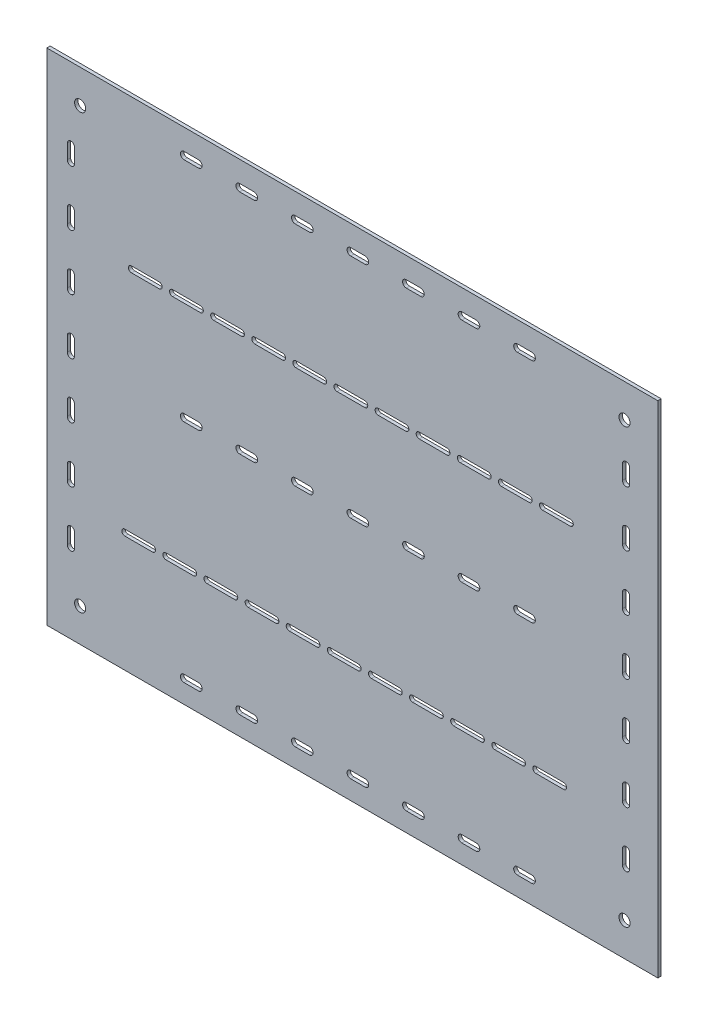
from build123d import *

# Parameters (mm, degrees)
CROQUIS1_W              = 550
CROQUIS1_H              = 450
CROQUIS1_R              = 5
SALIENTE_EXTRUIR1_DEPTH = 3


with BuildPart() as part:
    # Croquis1 → Saliente-Extruir1 (new body)
    with BuildSketch(Plane(origin=(0, 0, 0), x_dir=(-1, 0, 0), z_dir=(0, 0, -1))):
        Rectangle(CROQUIS1_W, CROQUIS1_H)
        with Locations((-245, -195)):
            Circle(CROQUIS1_R, mode=Mode.SUBTRACT)
        with Locations((245, -195)):
            Circle(CROQUIS1_R, mode=Mode.SUBTRACT)
        with Locations((-245, 195)):
            Circle(CROQUIS1_R, mode=Mode.SUBTRACT)
        with Locations((245, 195)):
            Circle(CROQUIS1_R, mode=Mode.SUBTRACT)
        with BuildLine():
            Line((250.09614838, 147), (250.09614838, 160))
            ThreePointArc((250.09614838, 160), (253.34614838, 163.25), (256.59614838, 160))
            Line((256.59614838, 160), (256.59614838, 147))
            ThreePointArc((256.59614838, 147), (253.34614838, 143.75), (250.09614838, 147))
        make_face(mode=Mode.SUBTRACT)
        with BuildLine():
            Line((19.81708851, -120.391388581), (-5.18291149, -120.391388581))
            ThreePointArc((-5.18291149, -120.391388581), (-7.88291149, -117.691388581), (-5.18291149, -114.991388581))
            Line((-5.18291149, -114.991388581), (19.81708851, -114.991388581))
            ThreePointArc((19.81708851, -114.991388581), (22.51708851, -117.691388581), (19.81708851, -120.391388581))
        make_face(mode=Mode.SUBTRACT)
        with BuildLine():
            Line((-128.18291149, -120.391388581), (-153.18291149, -120.391388581))
            ThreePointArc((-153.18291149, -120.391388581), (-155.88291149, -117.691388581), (-153.18291149, -114.991388581))
            Line((-153.18291149, -114.991388581), (-128.18291149, -114.991388581))
            ThreePointArc((-128.18291149, -114.991388581), (-125.48291149, -117.691388581), (-128.18291149, -120.391388581))
        make_face(mode=Mode.SUBTRACT)
        with BuildLine():
            Line((93.81708851, -120.391388581), (68.81708851, -120.391388581))
            ThreePointArc((68.81708851, -120.391388581), (66.11708851, -117.691388581), (68.81708851, -114.991388581))
            Line((68.81708851, -114.991388581), (93.81708851, -114.991388581))
            ThreePointArc((93.81708851, -114.991388581), (96.51708851, -117.691388581), (93.81708851, -120.391388581))
        make_face(mode=Mode.SUBTRACT)
        with BuildLine():
            Line((-17.18291149, -120.391388581), (-42.18291149, -120.391388581))
            ThreePointArc((-42.18291149, -120.391388581), (-44.88291149, -117.691388581), (-42.18291149, -114.991388581))
            Line((-42.18291149, -114.991388581), (-17.18291149, -114.991388581))
            ThreePointArc((-17.18291149, -114.991388581), (-14.48291149, -117.691388581), (-17.18291149, -120.391388581))
        make_face(mode=Mode.SUBTRACT)
        with BuildLine():
            Line((167.81708851, -120.391388581), (142.81708851, -120.391388581))
            ThreePointArc((142.81708851, -120.391388581), (140.11708851, -117.691388581), (142.81708851, -114.991388581))
            Line((142.81708851, -114.991388581), (167.81708851, -114.991388581))
            ThreePointArc((167.81708851, -114.991388581), (170.51708851, -117.691388581), (167.81708851, -120.391388581))
        make_face(mode=Mode.SUBTRACT)
        with BuildLine():
            Line((56.81708851, -120.391388581), (31.81708851, -120.391388581))
            ThreePointArc((31.81708851, -120.391388581), (29.11708851, -117.691388581), (31.81708851, -114.991388581))
            Line((31.81708851, -114.991388581), (56.81708851, -114.991388581))
            ThreePointArc((56.81708851, -114.991388581), (59.51708851, -117.691388581), (56.81708851, -120.391388581))
        make_face(mode=Mode.SUBTRACT)
        with BuildLine():
            Line((179.81708851, -114.991388581), (204.81708851, -114.991388581))
            ThreePointArc((204.81708851, -114.991388581), (207.51708851, -117.691388581), (204.81708851, -120.391388581))
            Line((204.81708851, -120.391388581), (179.81708851, -120.391388581))
            ThreePointArc((179.81708851, -120.391388581), (177.11708851, -117.691388581), (179.81708851, -114.991388581))
        make_face(mode=Mode.SUBTRACT)
        with BuildLine():
            Line((105.81708851, -114.991388581), (130.81708851, -114.991388581))
            ThreePointArc((130.81708851, -114.991388581), (133.51708851, -117.691388581), (130.81708851, -120.391388581))
            Line((130.81708851, -120.391388581), (105.81708851, -120.391388581))
            ThreePointArc((105.81708851, -120.391388581), (103.11708851, -117.691388581), (105.81708851, -114.991388581))
        make_face(mode=Mode.SUBTRACT)
        with BuildLine():
            Line((-171.181949448, 87.805486707), (-196.181949448, 87.805486707))
            ThreePointArc((-196.181949448, 87.805486707), (-198.881949448, 90.505486707), (-196.181949448, 93.205486707))
            Line((-196.181949448, 93.205486707), (-171.181949448, 93.205486707))
            ThreePointArc((-171.181949448, 93.205486707), (-168.481949448, 90.505486707), (-171.181949448, 87.805486707))
        make_face(mode=Mode.SUBTRACT)
        with BuildLine():
            Line((-60.181949448, 87.805486707), (-85.181949448, 87.805486707))
            ThreePointArc((-85.181949448, 87.805486707), (-87.881949448, 90.505486707), (-85.181949448, 93.205486707))
            Line((-85.181949448, 93.205486707), (-60.181949448, 93.205486707))
            ThreePointArc((-60.181949448, 93.205486707), (-57.481949448, 90.505486707), (-60.181949448, 87.805486707))
        make_face(mode=Mode.SUBTRACT)
        with BuildLine():
            Line((51.5, -4.75), (38.5, -4.75))
            ThreePointArc((38.5, -4.75), (35.25, -1.5), (38.5, 1.75))
            Line((38.5, 1.75), (51.5, 1.75))
            ThreePointArc((51.5, 1.75), (54.75, -1.5), (51.5, -4.75))
        make_face(mode=Mode.SUBTRACT)
        with BuildLine():
            Line((151.5, -4.75), (138.5, -4.75))
            ThreePointArc((138.5, -4.75), (135.25, -1.5), (138.5, 1.75))
            Line((138.5, 1.75), (151.5, 1.75))
            ThreePointArc((151.5, 1.75), (154.75, -1.5), (151.5, -4.75))
        make_face(mode=Mode.SUBTRACT)
        with BuildLine():
            Line((13.818050552, 87.805486707), (-11.181949448, 87.805486707))
            ThreePointArc((-11.181949448, 87.805486707), (-13.881949448, 90.505486707), (-11.181949448, 93.205486707))
            Line((-11.181949448, 93.205486707), (13.818050552, 93.205486707))
            ThreePointArc((13.818050552, 93.205486707), (16.518050552, 90.505486707), (13.818050552, 87.805486707))
        make_face(mode=Mode.SUBTRACT)
        with BuildLine():
            Line((-23.181949448, 87.805486707), (-48.181949448, 87.805486707))
            ThreePointArc((-48.181949448, 87.805486707), (-50.881949448, 90.505486707), (-48.181949448, 93.205486707))
            Line((-48.181949448, 93.205486707), (-23.181949448, 93.205486707))
            ThreePointArc((-23.181949448, 93.205486707), (-20.481949448, 90.505486707), (-23.181949448, 87.805486707))
        make_face(mode=Mode.SUBTRACT)
        with BuildLine():
            Line((-97.181949448, 87.805486707), (-122.181949448, 87.805486707))
            ThreePointArc((-122.181949448, 87.805486707), (-124.881949448, 90.505486707), (-122.181949448, 93.205486707))
            Line((-122.181949448, 93.205486707), (-97.181949448, 93.205486707))
            ThreePointArc((-97.181949448, 93.205486707), (-94.481949448, 90.505486707), (-97.181949448, 87.805486707))
        make_face(mode=Mode.SUBTRACT)
        with BuildLine():
            Line((-134.181949448, 87.805486707), (-159.181949448, 87.805486707))
            ThreePointArc((-159.181949448, 87.805486707), (-161.881949448, 90.505486707), (-159.181949448, 93.205486707))
            Line((-159.181949448, 93.205486707), (-134.181949448, 93.205486707))
            ThreePointArc((-134.181949448, 93.205486707), (-131.481949448, 90.505486707), (-134.181949448, 87.805486707))
        make_face(mode=Mode.SUBTRACT)
        with BuildLine():
            Line((50.818050552, 87.805486707), (25.818050552, 87.805486707))
            ThreePointArc((25.818050552, 87.805486707), (23.118050552, 90.505486707), (25.818050552, 93.205486707))
            Line((25.818050552, 93.205486707), (50.818050552, 93.205486707))
            ThreePointArc((50.818050552, 93.205486707), (53.518050552, 90.505486707), (50.818050552, 87.805486707))
        make_face(mode=Mode.SUBTRACT)
        with BuildLine():
            Line((87.818050552, 87.805486707), (62.818050552, 87.805486707))
            ThreePointArc((62.818050552, 87.805486707), (60.118050552, 90.505486707), (62.818050552, 93.205486707))
            Line((62.818050552, 93.205486707), (87.818050552, 93.205486707))
            ThreePointArc((87.818050552, 93.205486707), (90.518050552, 90.505486707), (87.818050552, 87.805486707))
        make_face(mode=Mode.SUBTRACT)
        with BuildLine():
            Line((-165.18291149, -120.391388581), (-190.18291149, -120.391388581))
            ThreePointArc((-190.18291149, -120.391388581), (-192.88291149, -117.691388581), (-190.18291149, -114.991388581))
            Line((-190.18291149, -114.991388581), (-165.18291149, -114.991388581))
            ThreePointArc((-165.18291149, -114.991388581), (-162.48291149, -117.691388581), (-165.18291149, -120.391388581))
        make_face(mode=Mode.SUBTRACT)
        with BuildLine():
            Line((161.818050552, 87.805486707), (136.818050552, 87.805486707))
            ThreePointArc((136.818050552, 87.805486707), (134.118050552, 90.505486707), (136.818050552, 93.205486707))
            Line((136.818050552, 93.205486707), (161.818050552, 93.205486707))
            ThreePointArc((161.818050552, 93.205486707), (164.518050552, 90.505486707), (161.818050552, 87.805486707))
        make_face(mode=Mode.SUBTRACT)
        with BuildLine():
            Line((-54.18291149, -120.391388581), (-79.18291149, -120.391388581))
            ThreePointArc((-79.18291149, -120.391388581), (-81.88291149, -117.691388581), (-79.18291149, -114.991388581))
            Line((-79.18291149, -114.991388581), (-54.18291149, -114.991388581))
            ThreePointArc((-54.18291149, -114.991388581), (-51.48291149, -117.691388581), (-54.18291149, -120.391388581))
        make_face(mode=Mode.SUBTRACT)
        with BuildLine():
            Line((-91.18291149, -120.391388581), (-116.18291149, -120.391388581))
            ThreePointArc((-116.18291149, -120.391388581), (-118.88291149, -117.691388581), (-116.18291149, -114.991388581))
            Line((-116.18291149, -114.991388581), (-91.18291149, -114.991388581))
            ThreePointArc((-91.18291149, -114.991388581), (-88.48291149, -117.691388581), (-91.18291149, -120.391388581))
        make_face(mode=Mode.SUBTRACT)
        with BuildLine():
            Line((99.818050552, 93.205486707), (124.818050552, 93.205486707))
            ThreePointArc((124.818050552, 93.205486707), (127.518050552, 90.505486707), (124.818050552, 87.805486707))
            Line((124.818050552, 87.805486707), (99.818050552, 87.805486707))
            ThreePointArc((99.818050552, 87.805486707), (97.118050552, 90.505486707), (99.818050552, 93.205486707))
        make_face(mode=Mode.SUBTRACT)
        with BuildLine():
            Line((173.818050552, 93.205486707), (198.818050552, 93.205486707))
            ThreePointArc((198.818050552, 93.205486707), (201.518050552, 90.505486707), (198.818050552, 87.805486707))
            Line((198.818050552, 87.805486707), (173.818050552, 87.805486707))
            ThreePointArc((173.818050552, 87.805486707), (171.118050552, 90.505486707), (173.818050552, 93.205486707))
        make_face(mode=Mode.SUBTRACT)
        with BuildLine():
            Line((-98.5, -4.75), (-111.5, -4.75))
            ThreePointArc((-111.5, -4.75), (-114.75, -1.5), (-111.5, 1.75))
            Line((-111.5, 1.75), (-98.5, 1.75))
            ThreePointArc((-98.5, 1.75), (-95.25, -1.5), (-98.5, -4.75))
        make_face(mode=Mode.SUBTRACT)
        with BuildLine():
            Line((101.5, -4.75), (88.5, -4.75))
            ThreePointArc((88.5, -4.75), (85.25, -1.5), (88.5, 1.75))
            Line((88.5, 1.75), (101.5, 1.75))
            ThreePointArc((101.5, 1.75), (104.75, -1.5), (101.5, -4.75))
        make_face(mode=Mode.SUBTRACT)
        with BuildLine():
            Line((1.5, -4.75), (-11.5, -4.75))
            ThreePointArc((-11.5, -4.75), (-14.75, -1.5), (-11.5, 1.75))
            Line((-11.5, 1.75), (1.5, 1.75))
            ThreePointArc((1.5, 1.75), (4.75, -1.5), (1.5, -4.75))
        make_face(mode=Mode.SUBTRACT)
        with BuildLine():
            Line((-48.5, -4.75), (-61.5, -4.75))
            ThreePointArc((-61.5, -4.75), (-64.75, -1.5), (-61.5, 1.75))
            Line((-61.5, 1.75), (-48.5, 1.75))
            ThreePointArc((-48.5, 1.75), (-45.25, -1.5), (-48.5, -4.75))
        make_face(mode=Mode.SUBTRACT)
        with BuildLine():
            Line((151.5, -207.959451093), (138.5, -207.959451093))
            ThreePointArc((138.5, -207.959451093), (135.25, -204.709451093), (138.5, -201.459451093))
            Line((138.5, -201.459451093), (151.5, -201.459451093))
            ThreePointArc((151.5, -201.459451093), (154.75, -204.709451093), (151.5, -207.959451093))
        make_face(mode=Mode.SUBTRACT)
        with BuildLine():
            Line((-148.5, -4.75), (-161.5, -4.75))
            ThreePointArc((-161.5, -4.75), (-164.75, -1.5), (-161.5, 1.75))
            Line((-161.5, 1.75), (-148.5, 1.75))
            ThreePointArc((-148.5, 1.75), (-145.25, -1.5), (-148.5, -4.75))
        make_face(mode=Mode.SUBTRACT)
        with BuildLine():
            Line((101.5, -207.959451093), (88.5, -207.959451093))
            ThreePointArc((88.5, -207.959451093), (85.25, -204.709451093), (88.5, -201.459451093))
            Line((88.5, -201.459451093), (101.5, -201.459451093))
            ThreePointArc((101.5, -201.459451093), (104.75, -204.709451093), (101.5, -207.959451093))
        make_face(mode=Mode.SUBTRACT)
        with BuildLine():
            Line((51.5, -207.959451093), (38.5, -207.959451093))
            ThreePointArc((38.5, -207.959451093), (35.25, -204.709451093), (38.5, -201.459451093))
            Line((38.5, -201.459451093), (51.5, -201.459451093))
            ThreePointArc((51.5, -201.459451093), (54.75, -204.709451093), (51.5, -207.959451093))
        make_face(mode=Mode.SUBTRACT)
        with BuildLine():
            Line((101.5, 199.605015398), (88.5, 199.605015398))
            ThreePointArc((88.5, 199.605015398), (85.25, 202.855015398), (88.5, 206.105015398))
            Line((88.5, 206.105015398), (101.5, 206.105015398))
            ThreePointArc((101.5, 206.105015398), (104.75, 202.855015398), (101.5, 199.605015398))
        make_face(mode=Mode.SUBTRACT)
        with BuildLine():
            Line((-98.5, 199.605015398), (-111.5, 199.605015398))
            ThreePointArc((-111.5, 199.605015398), (-114.75, 202.855015398), (-111.5, 206.105015398))
            Line((-111.5, 206.105015398), (-98.5, 206.105015398))
            ThreePointArc((-98.5, 206.105015398), (-95.25, 202.855015398), (-98.5, 199.605015398))
        make_face(mode=Mode.SUBTRACT)
        with BuildLine():
            Line((151.5, 199.605015398), (138.5, 199.605015398))
            ThreePointArc((138.5, 199.605015398), (135.25, 202.855015398), (138.5, 206.105015398))
            Line((138.5, 206.105015398), (151.5, 206.105015398))
            ThreePointArc((151.5, 206.105015398), (154.75, 202.855015398), (151.5, 199.605015398))
        make_face(mode=Mode.SUBTRACT)
        with BuildLine():
            Line((51.5, 199.605015398), (38.5, 199.605015398))
            ThreePointArc((38.5, 199.605015398), (35.25, 202.855015398), (38.5, 206.105015398))
            Line((38.5, 206.105015398), (51.5, 206.105015398))
            ThreePointArc((51.5, 206.105015398), (54.75, 202.855015398), (51.5, 199.605015398))
        make_face(mode=Mode.SUBTRACT)
        with BuildLine():
            Line((1.5, -207.959451093), (-11.5, -207.959451093))
            ThreePointArc((-11.5, -207.959451093), (-14.75, -204.709451093), (-11.5, -201.459451093))
            Line((-11.5, -201.459451093), (1.5, -201.459451093))
            ThreePointArc((1.5, -201.459451093), (4.75, -204.709451093), (1.5, -207.959451093))
        make_face(mode=Mode.SUBTRACT)
        with BuildLine():
            Line((-148.5, -207.959451093), (-161.5, -207.959451093))
            ThreePointArc((-161.5, -207.959451093), (-164.75, -204.709451093), (-161.5, -201.459451093))
            Line((-161.5, -201.459451093), (-148.5, -201.459451093))
            ThreePointArc((-148.5, -201.459451093), (-145.25, -204.709451093), (-148.5, -207.959451093))
        make_face(mode=Mode.SUBTRACT)
        with BuildLine():
            Line((-98.5, -207.959451093), (-111.5, -207.959451093))
            ThreePointArc((-111.5, -207.959451093), (-114.75, -204.709451093), (-111.5, -201.459451093))
            Line((-111.5, -201.459451093), (-98.5, -201.459451093))
            ThreePointArc((-98.5, -201.459451093), (-95.25, -204.709451093), (-98.5, -207.959451093))
        make_face(mode=Mode.SUBTRACT)
        with BuildLine():
            Line((-48.5, -207.959451093), (-61.5, -207.959451093))
            ThreePointArc((-61.5, -207.959451093), (-64.75, -204.709451093), (-61.5, -201.459451093))
            Line((-61.5, -201.459451093), (-48.5, -201.459451093))
            ThreePointArc((-48.5, -201.459451093), (-45.25, -204.709451093), (-48.5, -207.959451093))
        make_face(mode=Mode.SUBTRACT)
        with BuildLine():
            Line((-148.5, 199.605015398), (-161.5, 199.605015398))
            ThreePointArc((-161.5, 199.605015398), (-164.75, 202.855015398), (-161.5, 206.105015398))
            Line((-161.5, 206.105015398), (-148.5, 206.105015398))
            ThreePointArc((-148.5, 206.105015398), (-145.25, 202.855015398), (-148.5, 199.605015398))
        make_face(mode=Mode.SUBTRACT)
        with BuildLine():
            Line((-249.649280183, -153), (-249.649280183, -140))
            ThreePointArc((-249.649280183, -140), (-246.399280183, -136.75), (-243.149280183, -140))
            Line((-243.149280183, -140), (-243.149280183, -153))
            ThreePointArc((-243.149280183, -153), (-246.399280183, -156.25), (-249.649280183, -153))
        make_face(mode=Mode.SUBTRACT)
        with BuildLine():
            Line((-48.5, 199.605015398), (-61.5, 199.605015398))
            ThreePointArc((-61.5, 199.605015398), (-64.75, 202.855015398), (-61.5, 206.105015398))
            Line((-61.5, 206.105015398), (-48.5, 206.105015398))
            ThreePointArc((-48.5, 206.105015398), (-45.25, 202.855015398), (-48.5, 199.605015398))
        make_face(mode=Mode.SUBTRACT)
        with BuildLine():
            Line((1.5, 199.605015398), (-11.5, 199.605015398))
            ThreePointArc((-11.5, 199.605015398), (-14.75, 202.855015398), (-11.5, 206.105015398))
            Line((-11.5, 206.105015398), (1.5, 206.105015398))
            ThreePointArc((1.5, 206.105015398), (4.75, 202.855015398), (1.5, 199.605015398))
        make_face(mode=Mode.SUBTRACT)
        with BuildLine():
            Line((-249.649280183, 97), (-249.649280183, 110))
            ThreePointArc((-249.649280183, 110), (-246.399280183, 113.25), (-243.149280183, 110))
            Line((-243.149280183, 110), (-243.149280183, 97))
            ThreePointArc((-243.149280183, 97), (-246.399280183, 93.75), (-249.649280183, 97))
        make_face(mode=Mode.SUBTRACT)
        with BuildLine():
            Line((-249.649280183, 47), (-249.649280183, 60))
            ThreePointArc((-249.649280183, 60), (-246.399280183, 63.25), (-243.149280183, 60))
            Line((-243.149280183, 60), (-243.149280183, 47))
            ThreePointArc((-243.149280183, 47), (-246.399280183, 43.75), (-249.649280183, 47))
        make_face(mode=Mode.SUBTRACT)
        with BuildLine():
            Line((-249.649280183, -53), (-249.649280183, -40))
            ThreePointArc((-249.649280183, -40), (-246.399280183, -36.75), (-243.149280183, -40))
            Line((-243.149280183, -40), (-243.149280183, -53))
            ThreePointArc((-243.149280183, -53), (-246.399280183, -56.25), (-249.649280183, -53))
        make_face(mode=Mode.SUBTRACT)
        with BuildLine():
            Line((-249.649280183, -103), (-249.649280183, -90))
            ThreePointArc((-249.649280183, -90), (-246.399280183, -86.75), (-243.149280183, -90))
            Line((-243.149280183, -90), (-243.149280183, -103))
            ThreePointArc((-243.149280183, -103), (-246.399280183, -106.25), (-249.649280183, -103))
        make_face(mode=Mode.SUBTRACT)
        with BuildLine():
            Line((250.09614838, -153), (250.09614838, -140))
            ThreePointArc((250.09614838, -140), (253.34614838, -136.75), (256.59614838, -140))
            Line((256.59614838, -140), (256.59614838, -153))
            ThreePointArc((256.59614838, -153), (253.34614838, -156.25), (250.09614838, -153))
        make_face(mode=Mode.SUBTRACT)
        with BuildLine():
            Line((250.09614838, -53), (250.09614838, -40))
            ThreePointArc((250.09614838, -40), (253.34614838, -36.75), (256.59614838, -40))
            Line((256.59614838, -40), (256.59614838, -53))
            ThreePointArc((256.59614838, -53), (253.34614838, -56.25), (250.09614838, -53))
        make_face(mode=Mode.SUBTRACT)
        with BuildLine():
            Line((-249.649280183, -3), (-249.649280183, 10))
            ThreePointArc((-249.649280183, 10), (-246.399280183, 13.25), (-243.149280183, 10))
            Line((-243.149280183, 10), (-243.149280183, -3))
            ThreePointArc((-243.149280183, -3), (-246.399280183, -6.25), (-249.649280183, -3))
        make_face(mode=Mode.SUBTRACT)
        with BuildLine():
            Line((-249.649280183, 147), (-249.649280183, 160))
            ThreePointArc((-249.649280183, 160), (-246.399280183, 163.25), (-243.149280183, 160))
            Line((-243.149280183, 160), (-243.149280183, 147))
            ThreePointArc((-243.149280183, 147), (-246.399280183, 143.75), (-249.649280183, 147))
        make_face(mode=Mode.SUBTRACT)
        with BuildLine():
            Line((250.09614838, 97), (250.09614838, 110))
            ThreePointArc((250.09614838, 110), (253.34614838, 113.25), (256.59614838, 110))
            Line((256.59614838, 110), (256.59614838, 97))
            ThreePointArc((256.59614838, 97), (253.34614838, 93.75), (250.09614838, 97))
        make_face(mode=Mode.SUBTRACT)
        with BuildLine():
            Line((250.09614838, -103), (250.09614838, -90))
            ThreePointArc((250.09614838, -90), (253.34614838, -86.75), (256.59614838, -90))
            Line((256.59614838, -90), (256.59614838, -103))
            ThreePointArc((256.59614838, -103), (253.34614838, -106.25), (250.09614838, -103))
        make_face(mode=Mode.SUBTRACT)
        with BuildLine():
            Line((250.09614838, -3), (250.09614838, 10))
            ThreePointArc((250.09614838, 10), (253.34614838, 13.25), (256.59614838, 10))
            Line((256.59614838, 10), (256.59614838, -3))
            ThreePointArc((256.59614838, -3), (253.34614838, -6.25), (250.09614838, -3))
        make_face(mode=Mode.SUBTRACT)
        with BuildLine():
            Line((250.09614838, 47), (250.09614838, 60))
            ThreePointArc((250.09614838, 60), (253.34614838, 63.25), (256.59614838, 60))
            Line((256.59614838, 60), (256.59614838, 47))
            ThreePointArc((256.59614838, 47), (253.34614838, 43.75), (250.09614838, 47))
        make_face(mode=Mode.SUBTRACT)
    extrude(amount=-SALIENTE_EXTRUIR1_DEPTH)


solid = part.part
